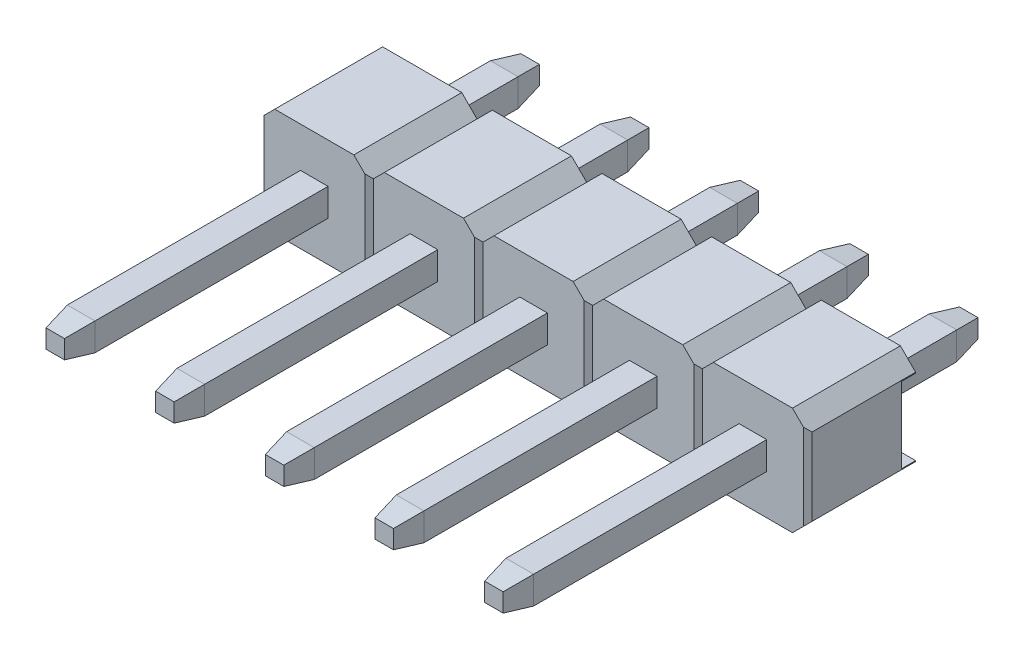
from build123d import *

# Parameters (mm, degrees)
EXTRUDE1_DEPTH          = 1.25
CUT_EXTRUDE3_DEPTH      = 2.25
LPATTERN4_COUNT         = 3
LPATTERN4_PITCH         = 2.54
LPATTERN4_COUNT_DIR2    = 3
LPATTERN4_PITCH_DIR2    = 2.54
SKETCH2_W               = 1.752893218
SKETCH2_H               = 0.33
CUT_EXTRUDE1_DEPTH      = 7.35
CUT_EXTRUDE1_DEPTH_BACK = 7.35
SKETCH3_W               = 11
SKETCH3_H               = 0.64
EXTRUDE_THIN1_DEPTH     = 0.32
LPATTERN5_COUNT         = 3
LPATTERN5_PITCH         = 2.54
LPATTERN5_COL_COUNT     = 3
LPATTERN5_COL_PITCH     = 2.54
CHAMFER2_SIZE           = 0.6
CHAMFER2_SIZE2          = 0.105796188
CHAMFER2_PART_2_SIZE    = 0.6
CHAMFER2_PART_2_SIZE2   = 0.105796188
CHAMFER2_PART_3_SIZE    = 0.6
CHAMFER2_PART_3_SIZE2   = 0.105796188
CHAMFER2_PART_4_SIZE    = 0.6
CHAMFER2_PART_4_SIZE2   = 0.105796188
CHAMFER2_PART_5_SIZE    = 0.6
CHAMFER2_PART_5_SIZE2   = 0.105796188
CHAMFER2_PART_6_SIZE    = 0.6
CHAMFER2_PART_6_SIZE2   = 0.105796188
CHAMFER2_PART_7_SIZE    = 0.6
CHAMFER2_PART_7_SIZE2   = 0.105796188
CHAMFER2_PART_8_SIZE    = 0.6
CHAMFER2_PART_8_SIZE2   = 0.105796188
CHAMFER2_PART_9_SIZE    = 0.6
CHAMFER2_PART_9_SIZE2   = 0.105796188
CHAMFER2_PART_10_SIZE   = 0.6
CHAMFER2_PART_10_SIZE2  = 0.105796188
CHAMFER2_PART_11_SIZE   = 0.6
CHAMFER2_PART_11_SIZE2  = 0.105796188
CHAMFER2_PART_12_SIZE   = 0.6
CHAMFER2_PART_12_SIZE2  = 0.105796188
CHAMFER2_PART_13_SIZE   = 0.6
CHAMFER2_PART_13_SIZE2  = 0.105796188
CHAMFER2_PART_14_SIZE   = 0.6
CHAMFER2_PART_14_SIZE2  = 0.105796188
CHAMFER2_PART_15_SIZE   = 0.6
CHAMFER2_PART_15_SIZE2  = 0.105796188
CHAMFER2_PART_16_SIZE   = 0.6
CHAMFER2_PART_16_SIZE2  = 0.105796188
CHAMFER2_PART_17_SIZE   = 0.6
CHAMFER2_PART_17_SIZE2  = 0.105796188
CHAMFER2_PART_18_SIZE   = 0.6
CHAMFER2_PART_18_SIZE2  = 0.105796188
CHAMFER2_PART_19_SIZE   = 0.6
CHAMFER2_PART_19_SIZE2  = 0.105796188
CHAMFER2_PART_20_SIZE   = 0.6
CHAMFER2_PART_20_SIZE2  = 0.105796188
CHAMFER2_PART_21_SIZE   = 0.6
CHAMFER2_PART_21_SIZE2  = 0.105796188
CHAMFER2_PART_22_SIZE   = 0.6
CHAMFER2_PART_22_SIZE2  = 0.105796188
CHAMFER2_PART_23_SIZE   = 0.6
CHAMFER2_PART_23_SIZE2  = 0.105796188
CHAMFER2_PART_24_SIZE   = 0.6
CHAMFER2_PART_24_SIZE2  = 0.105796188
CHAMFER2_PART_25_SIZE   = 0.6
CHAMFER2_PART_25_SIZE2  = 0.105796188
CHAMFER2_PART_26_SIZE   = 0.6
CHAMFER2_PART_26_SIZE2  = 0.105796188
CHAMFER2_PART_27_SIZE   = 0.6
CHAMFER2_PART_27_SIZE2  = 0.105796188
CHAMFER2_PART_28_SIZE   = 0.6
CHAMFER2_PART_28_SIZE2  = 0.105796188
CHAMFER2_PART_29_SIZE   = 0.6
CHAMFER2_PART_29_SIZE2  = 0.105796188
CHAMFER2_PART_30_SIZE   = 0.6
CHAMFER2_PART_30_SIZE2  = 0.105796188
CHAMFER2_PART_31_SIZE   = 0.6
CHAMFER2_PART_31_SIZE2  = 0.105796188
CHAMFER2_PART_32_SIZE   = 0.6
CHAMFER2_PART_32_SIZE2  = 0.105796188
CHAMFER2_PART_33_SIZE   = 0.6
CHAMFER2_PART_33_SIZE2  = 0.105796188
CHAMFER2_PART_34_SIZE   = 0.6
CHAMFER2_PART_34_SIZE2  = 0.105796188
CHAMFER2_PART_35_SIZE   = 0.6
CHAMFER2_PART_35_SIZE2  = 0.105796188
CHAMFER2_PART_36_SIZE   = 0.6
CHAMFER2_PART_36_SIZE2  = 0.105796188
CHAMFER2_PART_37_SIZE   = 0.6
CHAMFER2_PART_37_SIZE2  = 0.105796188
CHAMFER2_PART_38_SIZE   = 0.6
CHAMFER2_PART_38_SIZE2  = 0.105796188
CHAMFER2_PART_39_SIZE   = 0.6
CHAMFER2_PART_39_SIZE2  = 0.105796188
CHAMFER2_PART_40_SIZE   = 0.6
CHAMFER2_PART_40_SIZE2  = 0.105796188


with BuildPart() as part:
    # Sketch1 → Extrude1 (new body, symmetric)
    with BuildSketch(Plane.XY):
        Polygon((-1.27, 0.896446609), (-0.916446609, 1.25), (0.916446609, 1.25), (1.27, 0.896446609), (1.27, -0.896446609), (0.916446609, -1.25), (-0.916446609, -1.25), (-1.27, -0.896446609), align=None)
    extrude1 = extrude(amount=EXTRUDE1_DEPTH, both=True)

    # Sketch4 → Cut-Extrude3 (cut, symmetric)
    with BuildSketch(Plane(origin=(0, 0, 0), x_dir=(1, 0, 0), z_dir=(0, 1, 0))):
        Polygon((-1.27, -1.15), (-1.17, -1.25), (-1.27, -1.25), align=None)
        Polygon((1.17, -1.25), (1.27, -1.15), (1.27, -1.25), align=None)
    cut_extrude3 = extrude(amount=CUT_EXTRUDE3_DEPTH, both=True, mode=Mode.SUBTRACT)

    # LPattern4: Extrude1, Cut-Extrude3 3 × 3
    with Locations(*[Vector(-1, 0, 0) * (i * LPATTERN4_PITCH) + Vector(1, 0, 0) * (j * LPATTERN4_PITCH_DIR2) for i in range(LPATTERN4_COUNT) for j in range(LPATTERN4_COUNT_DIR2) if (i, j) != (0, 0)]):
        add(extrude1)
        add(cut_extrude3, mode=Mode.SUBTRACT)

    # Sketch2 → Cut-Extrude1 (cut, two sides)
    with BuildSketch(Plane(origin=(0, 0, 0), x_dir=(0, -1, 0), z_dir=(1, 0, 0))) as cut_extrude1_sk:
        with Locations((0, 1.085)):
            Rectangle(SKETCH2_W, SKETCH2_H)
    extrude(amount=CUT_EXTRUDE1_DEPTH, mode=Mode.SUBTRACT)
    extrude(cut_extrude1_sk.sketch, amount=-CUT_EXTRUDE1_DEPTH_BACK, mode=Mode.SUBTRACT)

    # Sketch3 → Extrude-Thin1 (add, symmetric)
    with BuildSketch(Plane(origin=(0, 0, 0), x_dir=(0, 0, -1), z_dir=(1, 0, 0))):
        with Locations((-1.75, 0)):
            Rectangle(SKETCH3_W, SKETCH3_H)
    extrude_thin1 = extrude(amount=EXTRUDE_THIN1_DEPTH, both=True)

    # LPattern5: Extrude-Thin1 ×3
    with Locations(*[(i * LPATTERN5_PITCH, 0, 0) for i in range(1, LPATTERN5_COUNT)]):
        add(extrude_thin1)

    # LPattern5 col: Extrude-Thin1 ×3
    with Locations(*[(-i * LPATTERN5_COL_PITCH, 0, 0) for i in range(1, LPATTERN5_COL_COUNT)]):
        add(extrude_thin1)

    # Chamfer2
    chamfer2_edges = [part.edges().sort_by_distance(p)[0] for p in [
        (0, -0.32, 7.25),
    ]]
    chamfer2_side = [part.faces().sort_by_distance(p)[0] for p in [
        (0, -0.32, 4.25),
    ]]
    chamfer(chamfer2_edges, length=CHAMFER2_SIZE, length2=CHAMFER2_SIZE2, reference=chamfer2_side[0])

    # Chamfer2 part 2
    chamfer2_part_2_edges = [part.edges().sort_by_distance(p)[0] for p in [
        (0, 0.32, -3.75),
    ]]
    chamfer2_part_2_side = [part.faces().sort_by_distance(p)[0] for p in [
        (0, 0.32, -2.335),
    ]]
    chamfer(chamfer2_part_2_edges, length=CHAMFER2_PART_2_SIZE, length2=CHAMFER2_PART_2_SIZE2, reference=chamfer2_part_2_side[0])

    # Chamfer2 part 3
    chamfer2_part_3_edges = [part.edges().sort_by_distance(p)[0] for p in [
        (-0.32, 0, 7.25),
    ]]
    chamfer2_part_3_side = [part.faces().sort_by_distance(p)[0] for p in [
        (-0.32, 0, 4.25),
    ]]
    chamfer(chamfer2_part_3_edges, length=CHAMFER2_PART_3_SIZE, length2=CHAMFER2_PART_3_SIZE2, reference=chamfer2_part_3_side[0])

    # Chamfer2 part 4
    chamfer2_part_4_edges = [part.edges().sort_by_distance(p)[0] for p in [
        (-0.32, 0, -3.75),
    ]]
    chamfer2_part_4_side = [part.faces().sort_by_distance(p)[0] for p in [
        (-0.32, 0, -2.335),
    ]]
    chamfer(chamfer2_part_4_edges, length=CHAMFER2_PART_4_SIZE, length2=CHAMFER2_PART_4_SIZE2, reference=chamfer2_part_4_side[0])

    # Chamfer2 part 5
    chamfer2_part_5_edges = [part.edges().sort_by_distance(p)[0] for p in [
        (0, -0.32, -3.75),
    ]]
    chamfer2_part_5_side = [part.faces().sort_by_distance(p)[0] for p in [
        (0, -0.32, -2.335),
    ]]
    chamfer(chamfer2_part_5_edges, length=CHAMFER2_PART_5_SIZE, length2=CHAMFER2_PART_5_SIZE2, reference=chamfer2_part_5_side[0])

    # Chamfer2 part 6
    chamfer2_part_6_edges = [part.edges().sort_by_distance(p)[0] for p in [
        (0.32, 0, -3.75),
    ]]
    chamfer2_part_6_side = [part.faces().sort_by_distance(p)[0] for p in [
        (0.32, 0, -2.335),
    ]]
    chamfer(chamfer2_part_6_edges, length=CHAMFER2_PART_6_SIZE, length2=CHAMFER2_PART_6_SIZE2, reference=chamfer2_part_6_side[0])

    # Chamfer2 part 7
    chamfer2_part_7_edges = [part.edges().sort_by_distance(p)[0] for p in [
        (0, 0.32, 7.25),
    ]]
    chamfer2_part_7_side = [part.faces().sort_by_distance(p)[0] for p in [
        (0, 0.32, 4.25),
    ]]
    chamfer(chamfer2_part_7_edges, length=CHAMFER2_PART_7_SIZE, length2=CHAMFER2_PART_7_SIZE2, reference=chamfer2_part_7_side[0])

    # Chamfer2 part 8
    chamfer2_part_8_edges = [part.edges().sort_by_distance(p)[0] for p in [
        (0.32, 0, 7.25),
    ]]
    chamfer2_part_8_side = [part.faces().sort_by_distance(p)[0] for p in [
        (0.32, 0, 4.25),
    ]]
    chamfer(chamfer2_part_8_edges, length=CHAMFER2_PART_8_SIZE, length2=CHAMFER2_PART_8_SIZE2, reference=chamfer2_part_8_side[0])

    # Chamfer2 part 9
    chamfer2_part_9_edges = [part.edges().sort_by_distance(p)[0] for p in [
        (-2.54, -0.32, 7.25),
    ]]
    chamfer2_part_9_side = [part.faces().sort_by_distance(p)[0] for p in [
        (-2.54, -0.32, 4.25),
    ]]
    chamfer(chamfer2_part_9_edges, length=CHAMFER2_PART_9_SIZE, length2=CHAMFER2_PART_9_SIZE2, reference=chamfer2_part_9_side[0])

    # Chamfer2 part 10
    chamfer2_part_10_edges = [part.edges().sort_by_distance(p)[0] for p in [
        (-2.54, 0.32, -3.75),
    ]]
    chamfer2_part_10_side = [part.faces().sort_by_distance(p)[0] for p in [
        (-2.54, 0.32, -2.335),
    ]]
    chamfer(chamfer2_part_10_edges, length=CHAMFER2_PART_10_SIZE, length2=CHAMFER2_PART_10_SIZE2, reference=chamfer2_part_10_side[0])

    # Chamfer2 part 11
    chamfer2_part_11_edges = [part.edges().sort_by_distance(p)[0] for p in [
        (-2.86, 0, -3.75),
    ]]
    chamfer2_part_11_side = [part.faces().sort_by_distance(p)[0] for p in [
        (-2.86, 0, -2.335),
    ]]
    chamfer(chamfer2_part_11_edges, length=CHAMFER2_PART_11_SIZE, length2=CHAMFER2_PART_11_SIZE2, reference=chamfer2_part_11_side[0])

    # Chamfer2 part 12
    chamfer2_part_12_edges = [part.edges().sort_by_distance(p)[0] for p in [
        (-2.86, 0, 7.25),
    ]]
    chamfer2_part_12_side = [part.faces().sort_by_distance(p)[0] for p in [
        (-2.86, 0, 4.25),
    ]]
    chamfer(chamfer2_part_12_edges, length=CHAMFER2_PART_12_SIZE, length2=CHAMFER2_PART_12_SIZE2, reference=chamfer2_part_12_side[0])

    # Chamfer2 part 13
    chamfer2_part_13_edges = [part.edges().sort_by_distance(p)[0] for p in [
        (-2.54, -0.32, -3.75),
    ]]
    chamfer2_part_13_side = [part.faces().sort_by_distance(p)[0] for p in [
        (-2.54, -0.32, -2.335),
    ]]
    chamfer(chamfer2_part_13_edges, length=CHAMFER2_PART_13_SIZE, length2=CHAMFER2_PART_13_SIZE2, reference=chamfer2_part_13_side[0])

    # Chamfer2 part 14
    chamfer2_part_14_edges = [part.edges().sort_by_distance(p)[0] for p in [
        (-2.22, 0, -3.75),
    ]]
    chamfer2_part_14_side = [part.faces().sort_by_distance(p)[0] for p in [
        (-2.22, 0, -2.335),
    ]]
    chamfer(chamfer2_part_14_edges, length=CHAMFER2_PART_14_SIZE, length2=CHAMFER2_PART_14_SIZE2, reference=chamfer2_part_14_side[0])

    # Chamfer2 part 15
    chamfer2_part_15_edges = [part.edges().sort_by_distance(p)[0] for p in [
        (-2.54, 0.32, 7.25),
    ]]
    chamfer2_part_15_side = [part.faces().sort_by_distance(p)[0] for p in [
        (-2.54, 0.32, 4.25),
    ]]
    chamfer(chamfer2_part_15_edges, length=CHAMFER2_PART_15_SIZE, length2=CHAMFER2_PART_15_SIZE2, reference=chamfer2_part_15_side[0])

    # Chamfer2 part 16
    chamfer2_part_16_edges = [part.edges().sort_by_distance(p)[0] for p in [
        (-2.22, 0, 7.25),
    ]]
    chamfer2_part_16_side = [part.faces().sort_by_distance(p)[0] for p in [
        (-2.22, 0, 4.25),
    ]]
    chamfer(chamfer2_part_16_edges, length=CHAMFER2_PART_16_SIZE, length2=CHAMFER2_PART_16_SIZE2, reference=chamfer2_part_16_side[0])

    # Chamfer2 part 17
    chamfer2_part_17_edges = [part.edges().sort_by_distance(p)[0] for p in [
        (-5.08, -0.32, 7.25),
    ]]
    chamfer2_part_17_side = [part.faces().sort_by_distance(p)[0] for p in [
        (-5.08, -0.32, 4.25),
    ]]
    chamfer(chamfer2_part_17_edges, length=CHAMFER2_PART_17_SIZE, length2=CHAMFER2_PART_17_SIZE2, reference=chamfer2_part_17_side[0])

    # Chamfer2 part 18
    chamfer2_part_18_edges = [part.edges().sort_by_distance(p)[0] for p in [
        (-5.08, 0.32, -3.75),
    ]]
    chamfer2_part_18_side = [part.faces().sort_by_distance(p)[0] for p in [
        (-5.08, 0.32, -2.335),
    ]]
    chamfer(chamfer2_part_18_edges, length=CHAMFER2_PART_18_SIZE, length2=CHAMFER2_PART_18_SIZE2, reference=chamfer2_part_18_side[0])

    # Chamfer2 part 19
    chamfer2_part_19_edges = [part.edges().sort_by_distance(p)[0] for p in [
        (-5.4, 0, -3.75),
    ]]
    chamfer2_part_19_side = [part.faces().sort_by_distance(p)[0] for p in [
        (-5.4, 0, -2.335),
    ]]
    chamfer(chamfer2_part_19_edges, length=CHAMFER2_PART_19_SIZE, length2=CHAMFER2_PART_19_SIZE2, reference=chamfer2_part_19_side[0])

    # Chamfer2 part 20
    chamfer2_part_20_edges = [part.edges().sort_by_distance(p)[0] for p in [
        (-5.4, 0, 7.25),
    ]]
    chamfer2_part_20_side = [part.faces().sort_by_distance(p)[0] for p in [
        (-5.4, 0, 4.25),
    ]]
    chamfer(chamfer2_part_20_edges, length=CHAMFER2_PART_20_SIZE, length2=CHAMFER2_PART_20_SIZE2, reference=chamfer2_part_20_side[0])

    # Chamfer2 part 21
    chamfer2_part_21_edges = [part.edges().sort_by_distance(p)[0] for p in [
        (-5.08, -0.32, -3.75),
    ]]
    chamfer2_part_21_side = [part.faces().sort_by_distance(p)[0] for p in [
        (-5.08, -0.32, -2.335),
    ]]
    chamfer(chamfer2_part_21_edges, length=CHAMFER2_PART_21_SIZE, length2=CHAMFER2_PART_21_SIZE2, reference=chamfer2_part_21_side[0])

    # Chamfer2 part 22
    chamfer2_part_22_edges = [part.edges().sort_by_distance(p)[0] for p in [
        (-4.76, 0, -3.75),
    ]]
    chamfer2_part_22_side = [part.faces().sort_by_distance(p)[0] for p in [
        (-4.76, 0, -2.335),
    ]]
    chamfer(chamfer2_part_22_edges, length=CHAMFER2_PART_22_SIZE, length2=CHAMFER2_PART_22_SIZE2, reference=chamfer2_part_22_side[0])

    # Chamfer2 part 23
    chamfer2_part_23_edges = [part.edges().sort_by_distance(p)[0] for p in [
        (-5.08, 0.32, 7.25),
    ]]
    chamfer2_part_23_side = [part.faces().sort_by_distance(p)[0] for p in [
        (-5.08, 0.32, 4.25),
    ]]
    chamfer(chamfer2_part_23_edges, length=CHAMFER2_PART_23_SIZE, length2=CHAMFER2_PART_23_SIZE2, reference=chamfer2_part_23_side[0])

    # Chamfer2 part 24
    chamfer2_part_24_edges = [part.edges().sort_by_distance(p)[0] for p in [
        (-4.76, 0, 7.25),
    ]]
    chamfer2_part_24_side = [part.faces().sort_by_distance(p)[0] for p in [
        (-4.76, 0, 4.25),
    ]]
    chamfer(chamfer2_part_24_edges, length=CHAMFER2_PART_24_SIZE, length2=CHAMFER2_PART_24_SIZE2, reference=chamfer2_part_24_side[0])

    # Chamfer2 part 25
    chamfer2_part_25_edges = [part.edges().sort_by_distance(p)[0] for p in [
        (2.54, -0.32, 7.25),
    ]]
    chamfer2_part_25_side = [part.faces().sort_by_distance(p)[0] for p in [
        (2.54, -0.32, 4.25),
    ]]
    chamfer(chamfer2_part_25_edges, length=CHAMFER2_PART_25_SIZE, length2=CHAMFER2_PART_25_SIZE2, reference=chamfer2_part_25_side[0])

    # Chamfer2 part 26
    chamfer2_part_26_edges = [part.edges().sort_by_distance(p)[0] for p in [
        (2.54, 0.32, -3.75),
    ]]
    chamfer2_part_26_side = [part.faces().sort_by_distance(p)[0] for p in [
        (2.54, 0.32, -2.335),
    ]]
    chamfer(chamfer2_part_26_edges, length=CHAMFER2_PART_26_SIZE, length2=CHAMFER2_PART_26_SIZE2, reference=chamfer2_part_26_side[0])

    # Chamfer2 part 27
    chamfer2_part_27_edges = [part.edges().sort_by_distance(p)[0] for p in [
        (2.22, 0, -3.75),
    ]]
    chamfer2_part_27_side = [part.faces().sort_by_distance(p)[0] for p in [
        (2.22, 0, -2.335),
    ]]
    chamfer(chamfer2_part_27_edges, length=CHAMFER2_PART_27_SIZE, length2=CHAMFER2_PART_27_SIZE2, reference=chamfer2_part_27_side[0])

    # Chamfer2 part 28
    chamfer2_part_28_edges = [part.edges().sort_by_distance(p)[0] for p in [
        (2.22, 0, 7.25),
    ]]
    chamfer2_part_28_side = [part.faces().sort_by_distance(p)[0] for p in [
        (2.22, 0, 4.25),
    ]]
    chamfer(chamfer2_part_28_edges, length=CHAMFER2_PART_28_SIZE, length2=CHAMFER2_PART_28_SIZE2, reference=chamfer2_part_28_side[0])

    # Chamfer2 part 29
    chamfer2_part_29_edges = [part.edges().sort_by_distance(p)[0] for p in [
        (2.54, -0.32, -3.75),
    ]]
    chamfer2_part_29_side = [part.faces().sort_by_distance(p)[0] for p in [
        (2.54, -0.32, -2.335),
    ]]
    chamfer(chamfer2_part_29_edges, length=CHAMFER2_PART_29_SIZE, length2=CHAMFER2_PART_29_SIZE2, reference=chamfer2_part_29_side[0])

    # Chamfer2 part 30
    chamfer2_part_30_edges = [part.edges().sort_by_distance(p)[0] for p in [
        (2.86, 0, -3.75),
    ]]
    chamfer2_part_30_side = [part.faces().sort_by_distance(p)[0] for p in [
        (2.86, 0, -2.335),
    ]]
    chamfer(chamfer2_part_30_edges, length=CHAMFER2_PART_30_SIZE, length2=CHAMFER2_PART_30_SIZE2, reference=chamfer2_part_30_side[0])

    # Chamfer2 part 31
    chamfer2_part_31_edges = [part.edges().sort_by_distance(p)[0] for p in [
        (2.54, 0.32, 7.25),
    ]]
    chamfer2_part_31_side = [part.faces().sort_by_distance(p)[0] for p in [
        (2.54, 0.32, 4.25),
    ]]
    chamfer(chamfer2_part_31_edges, length=CHAMFER2_PART_31_SIZE, length2=CHAMFER2_PART_31_SIZE2, reference=chamfer2_part_31_side[0])

    # Chamfer2 part 32
    chamfer2_part_32_edges = [part.edges().sort_by_distance(p)[0] for p in [
        (2.86, 0, 7.25),
    ]]
    chamfer2_part_32_side = [part.faces().sort_by_distance(p)[0] for p in [
        (2.86, 0, 4.25),
    ]]
    chamfer(chamfer2_part_32_edges, length=CHAMFER2_PART_32_SIZE, length2=CHAMFER2_PART_32_SIZE2, reference=chamfer2_part_32_side[0])

    # Chamfer2 part 33
    chamfer2_part_33_edges = [part.edges().sort_by_distance(p)[0] for p in [
        (5.08, -0.32, 7.25),
    ]]
    chamfer2_part_33_side = [part.faces().sort_by_distance(p)[0] for p in [
        (5.08, -0.32, 4.25),
    ]]
    chamfer(chamfer2_part_33_edges, length=CHAMFER2_PART_33_SIZE, length2=CHAMFER2_PART_33_SIZE2, reference=chamfer2_part_33_side[0])

    # Chamfer2 part 34
    chamfer2_part_34_edges = [part.edges().sort_by_distance(p)[0] for p in [
        (5.08, 0.32, -3.75),
    ]]
    chamfer2_part_34_side = [part.faces().sort_by_distance(p)[0] for p in [
        (5.08, 0.32, -2.335),
    ]]
    chamfer(chamfer2_part_34_edges, length=CHAMFER2_PART_34_SIZE, length2=CHAMFER2_PART_34_SIZE2, reference=chamfer2_part_34_side[0])

    # Chamfer2 part 35
    chamfer2_part_35_edges = [part.edges().sort_by_distance(p)[0] for p in [
        (4.76, 0, -3.75),
    ]]
    chamfer2_part_35_side = [part.faces().sort_by_distance(p)[0] for p in [
        (4.76, 0, -2.335),
    ]]
    chamfer(chamfer2_part_35_edges, length=CHAMFER2_PART_35_SIZE, length2=CHAMFER2_PART_35_SIZE2, reference=chamfer2_part_35_side[0])

    # Chamfer2 part 36
    chamfer2_part_36_edges = [part.edges().sort_by_distance(p)[0] for p in [
        (4.76, 0, 7.25),
    ]]
    chamfer2_part_36_side = [part.faces().sort_by_distance(p)[0] for p in [
        (4.76, 0, 4.25),
    ]]
    chamfer(chamfer2_part_36_edges, length=CHAMFER2_PART_36_SIZE, length2=CHAMFER2_PART_36_SIZE2, reference=chamfer2_part_36_side[0])

    # Chamfer2 part 37
    chamfer2_part_37_edges = [part.edges().sort_by_distance(p)[0] for p in [
        (5.08, -0.32, -3.75),
    ]]
    chamfer2_part_37_side = [part.faces().sort_by_distance(p)[0] for p in [
        (5.08, -0.32, -2.335),
    ]]
    chamfer(chamfer2_part_37_edges, length=CHAMFER2_PART_37_SIZE, length2=CHAMFER2_PART_37_SIZE2, reference=chamfer2_part_37_side[0])

    # Chamfer2 part 38
    chamfer2_part_38_edges = [part.edges().sort_by_distance(p)[0] for p in [
        (5.4, 0, -3.75),
    ]]
    chamfer2_part_38_side = [part.faces().sort_by_distance(p)[0] for p in [
        (5.4, 0, -2.335),
    ]]
    chamfer(chamfer2_part_38_edges, length=CHAMFER2_PART_38_SIZE, length2=CHAMFER2_PART_38_SIZE2, reference=chamfer2_part_38_side[0])

    # Chamfer2 part 39
    chamfer2_part_39_edges = [part.edges().sort_by_distance(p)[0] for p in [
        (5.08, 0.32, 7.25),
    ]]
    chamfer2_part_39_side = [part.faces().sort_by_distance(p)[0] for p in [
        (5.08, 0.32, 4.25),
    ]]
    chamfer(chamfer2_part_39_edges, length=CHAMFER2_PART_39_SIZE, length2=CHAMFER2_PART_39_SIZE2, reference=chamfer2_part_39_side[0])

    # Chamfer2 part 40
    chamfer2_part_40_edges = [part.edges().sort_by_distance(p)[0] for p in [
        (5.4, 0, 7.25),
    ]]
    chamfer2_part_40_side = [part.faces().sort_by_distance(p)[0] for p in [
        (5.4, 0, 4.25),
    ]]
    chamfer(chamfer2_part_40_edges, length=CHAMFER2_PART_40_SIZE, length2=CHAMFER2_PART_40_SIZE2, reference=chamfer2_part_40_side[0])


solid = part.part
